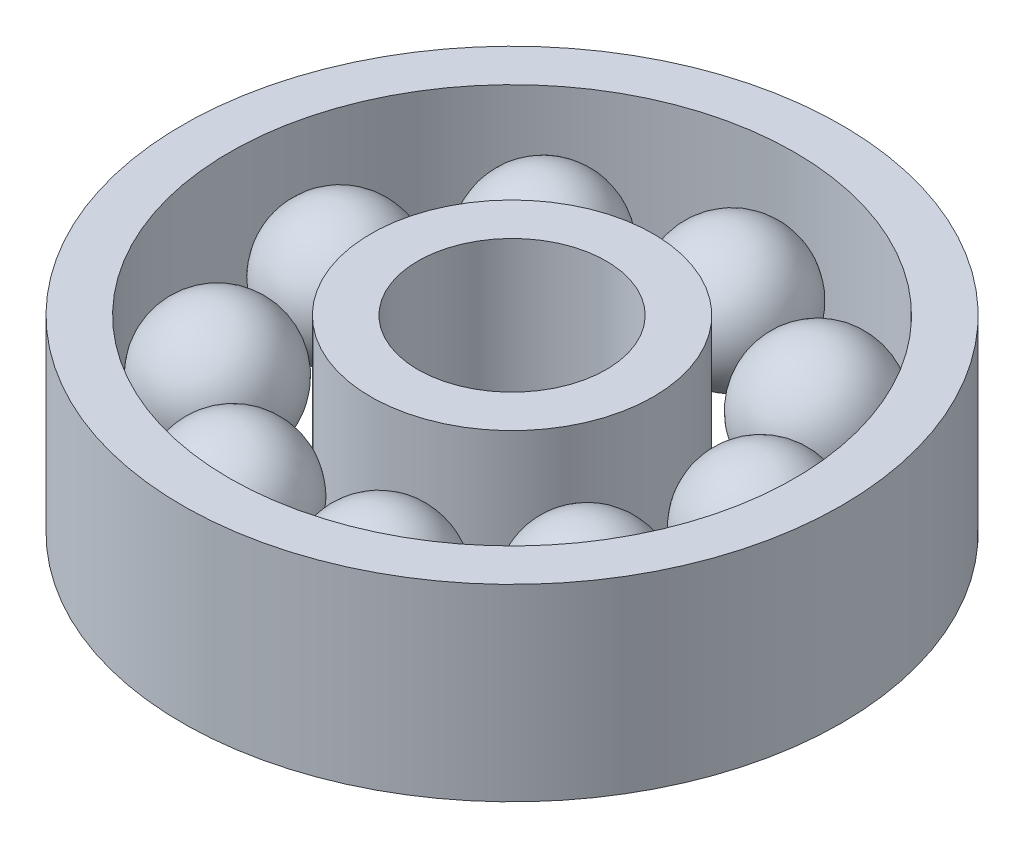
from build123d import *

# Parameters (mm, degrees)
SKETCH1_R             = 6
SKETCH1_R_2           = 4
EXTRUDE_THIN1_DEPTH   = 4
SKETCH1_R_3           = 14
SKETCH1_R_4           = 12
EXTRUDE_THIN1_2_DEPTH = 4
CIRPATTERN1_COUNT     = 9


with BuildPart() as part:
    # Sketch1 → Extrude-Thin1 (new body, symmetric)
    with BuildSketch(Plane(origin=(0, 0, 0), x_dir=(1, 0, 0), z_dir=(0, 1, 0))):
        Circle(SKETCH1_R)
        Circle(SKETCH1_R_2, mode=Mode.SUBTRACT)
    extrude(amount=EXTRUDE_THIN1_DEPTH, both=True)


with BuildPart() as body_2:
    # Sketch1 → Extrude-Thin1 2 (new body, symmetric)
    with BuildSketch(Plane(origin=(0, 0, 0), x_dir=(1, 0, 0), z_dir=(0, 1, 0))):
        Circle(SKETCH1_R_3)
        Circle(SKETCH1_R_4, mode=Mode.SUBTRACT)
    extrude(amount=EXTRUDE_THIN1_2_DEPTH, both=True)

    # Sketch2 → Revolve1 (revolve)
    with BuildSketch(Plane(origin=(0, 0, 0), x_dir=(1, 0, 0), z_dir=(0, 1, 0))):
        with BuildLine():
            Line((0.089520386, 11.999666083), (0.168325539, 6.400220597))
            ThreePointArc((0.168325539, 6.400220597), (2.928645706, 9.239345917), (0.089520386, 11.999666083))
        make_face()
    revolve1 = revolve(axis=Axis((0.089520386, 0, -11.999666083), (0.014072349, 0, 0.99990098)))

    # CirPattern1: Revolve1 ×9 about axis
    cirpattern1_axis = Axis((0, 0, 0), (0, 1, 0))
    for i in range(1, CIRPATTERN1_COUNT):
        add(revolve1.rotate(cirpattern1_axis, i * 360 / CIRPATTERN1_COUNT))


solid = Compound([part.part, body_2.part])
